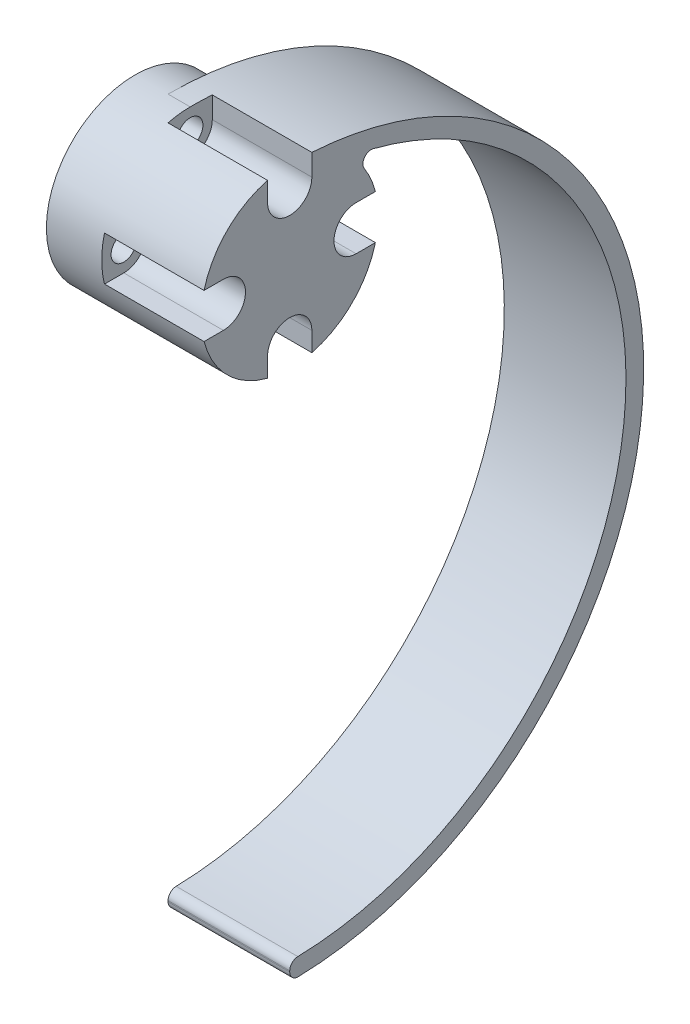
from build123d import *

# Parameters (mm, degrees)
HUB_SKETCH_R    = 8
HUB_SKETCH_R_2  = 1.15
HUB_DEPTH       = 11
HUB_DEPTH_BACK  = 3
LEG_DEPTH       = 11
CLEARANCE_DEPTH = 9
FILLET_2_R      = 0.75


with BuildPart() as part:
    # Hub-Sketch → Hub (new body, two sides)
    with BuildSketch(Plane(origin=(0, 0, 0), x_dir=(0, 0, -1), z_dir=(1, 0, 0))) as hub_sk:
        Circle(HUB_SKETCH_R)
        with Locations((0, 6)):
            Circle(HUB_SKETCH_R_2, mode=Mode.SUBTRACT)
        with Locations((-6, 0)):
            Circle(HUB_SKETCH_R_2, mode=Mode.SUBTRACT)
        with Locations((0, -6)):
            Circle(HUB_SKETCH_R_2, mode=Mode.SUBTRACT)
        with Locations((6, 0)):
            Circle(HUB_SKETCH_R_2, mode=Mode.SUBTRACT)
    extrude(amount=HUB_DEPTH)
    extrude(hub_sk.sketch, amount=-HUB_DEPTH_BACK)

    # Leg-Sketch → Leg (add)
    with BuildSketch(Plane(origin=(11, 0, 0), x_dir=(0, 0, -1), z_dir=(1, 0, 0))):
        with BuildLine():
            Line((0, -56), (0, -54.4))
            ThreePointArc((0, -54.4), (30.279762218, -26.701110883), (5.380854951, 5.92))
            ThreePointArc((5.380854951, 5.92), (2.88444102, 7.461903242), (0, 8))
            ThreePointArc((0, 8), (32, -24), (0, -56))
        make_face()
    extrude(amount=-LEG_DEPTH)

    # Clearance-Sketch → Clearance (cut)
    with BuildSketch(Plane(origin=(11, 0, 0), x_dir=(0, 0, -1), z_dir=(1, 0, 0))):
        with BuildLine():
            Line((-2, 8), (2, 8))
            Line((2, 8), (2, 6))
            ThreePointArc((2, 6), (0, 4), (-2, 6))
            Line((-2, 6), (-2, 8))
        make_face()
        with BuildLine():
            Line((8, 2), (8, -2))
            Line((8, -2), (6, -2))
            ThreePointArc((6, -2), (4, 0), (6, 2))
            Line((6, 2), (8, 2))
        make_face()
        with BuildLine():
            Line((2, -8), (-2, -8))
            Line((-2, -8), (-2, -6))
            ThreePointArc((-2, -6), (0, -4), (2, -6))
            Line((2, -6), (2, -8))
        make_face()
        with BuildLine():
            Line((-8, -2), (-8, 2))
            Line((-8, 2), (-6, 2))
            ThreePointArc((-6, 2), (-4, 0), (-6, -2))
            Line((-6, -2), (-8, -2))
        make_face()
    extrude(amount=-CLEARANCE_DEPTH, mode=Mode.SUBTRACT)

    # Fillet 2
    fillet_2_edges = [part.edges().sort_by_distance(p)[0] for p in [
        (5.5, 5.92, -5.380854951),
        (5.5, -56, 0),
        (5.5, -54.4, 0),
    ]]
    fillet(fillet_2_edges, radius=FILLET_2_R)


solid = part.part
